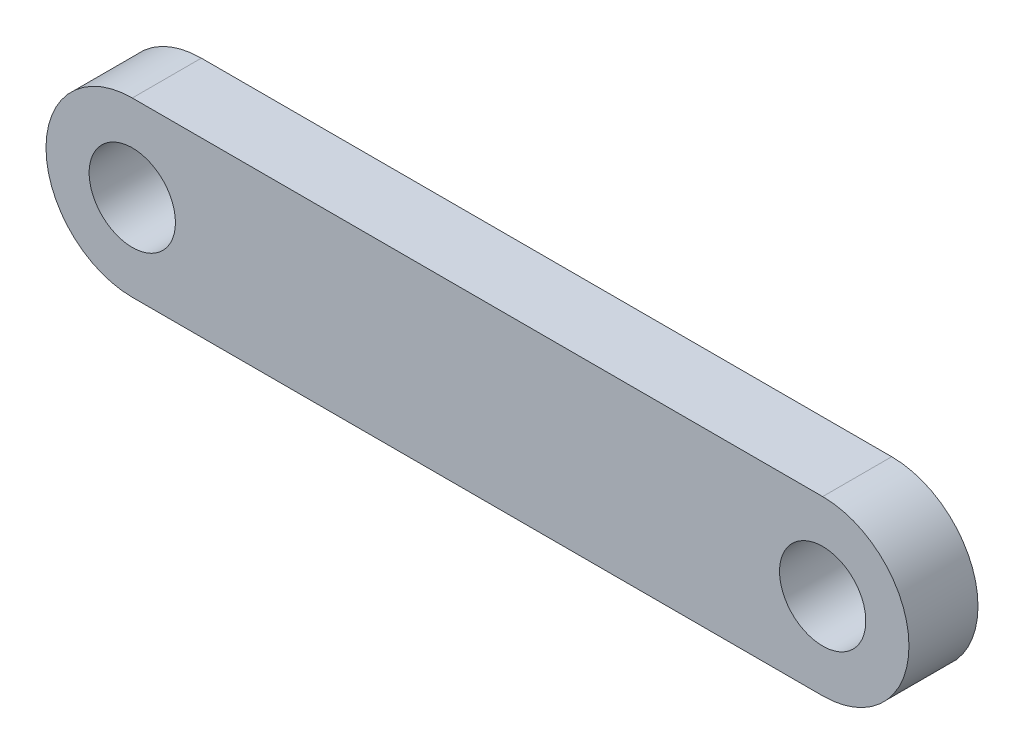
from build123d import *

# Parameters (mm, degrees)
SKETCH1_R           = 3.175
BOSS_EXTRUDE1_DEPTH = 5.08


with BuildPart() as part:
    # Sketch1 → Boss-Extrude1 (new body)
    with BuildSketch(Plane.XY):
        with BuildLine():
            Line((-25.4, 6.35), (25.4, 6.35))
            ThreePointArc((25.4, 6.35), (31.75, 0), (25.4, -6.35))
            Line((25.4, -6.35), (-25.4, -6.35))
            ThreePointArc((-25.4, -6.35), (-31.75, 0), (-25.4, 6.35))
        make_face()
        with Locations((-25.4, 0)):
            Circle(SKETCH1_R, mode=Mode.SUBTRACT)
        with Locations((25.4, 0)):
            Circle(SKETCH1_R, mode=Mode.SUBTRACT)
    extrude(amount=BOSS_EXTRUDE1_DEPTH)


solid = part.part
